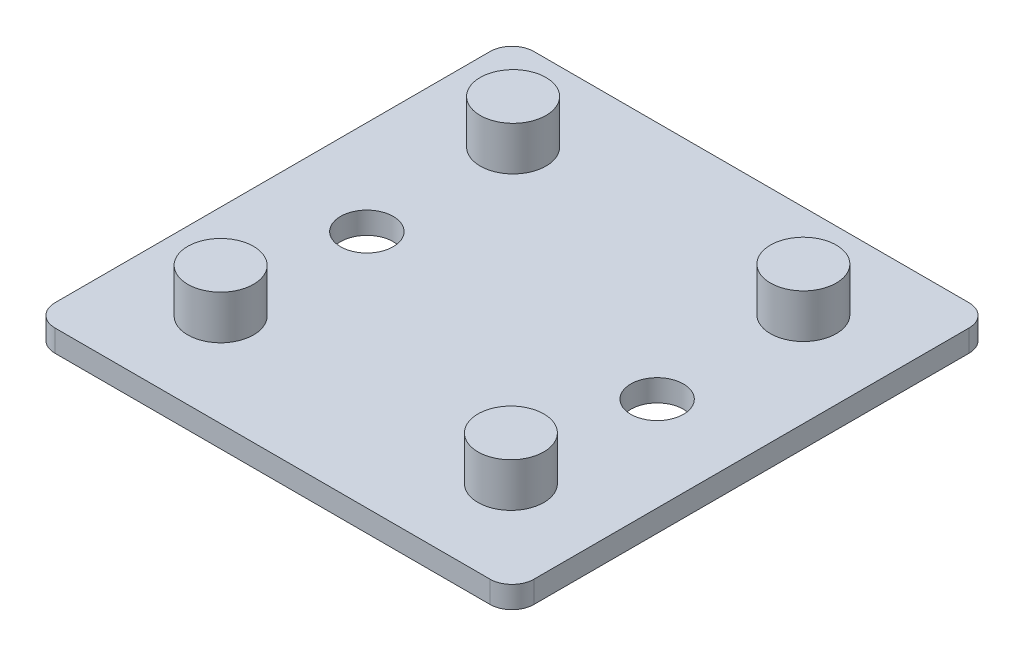
from build123d import *

# Parameters (mm, degrees)
SKETCH1_W               = 65.5
SKETCH1_H               = 65.5
BOSS_EXTRUDE1_DEPTH     = 3
FILLET1_R               = 3
SKETCH2_R               = 3.6
CUT_EXTRUDE1_DEPTH      = 23
SKETCH3_R               = 4.5
BOSS_EXTRUDE2_DEPTH     = 6
SKETCH4_R               = 3.6
CUT_EXTRUDE2_DEPTH      = 7
CUT_EXTRUDE2_DEPTH_BACK = 4


with BuildPart() as part:
    # Sketch1 → Boss-Extrude1 (new body)
    with BuildSketch(Plane(origin=(0, 0, 0), x_dir=(1, 0, 0), z_dir=(0, 1, 0))):
        Rectangle(SKETCH1_W, SKETCH1_H)
    extrude(amount=BOSS_EXTRUDE1_DEPTH)

    # Fillet1
    fillet1_edges = [part.edges().sort_by_distance(p)[0] for p in [
        (-32.75, 1.5, -32.75),
        (32.75, 1.5, -32.75),
        (32.75, 1.5, 32.75),
        (-32.75, 1.5, 32.75),
    ]]
    fillet(fillet1_edges, radius=FILLET1_R)

    # Sketch2 → Cut-Extrude1 (cut)
    with BuildSketch(Plane(origin=(0, 3, 0), x_dir=(1, 0, 0), z_dir=(0, 1, 0))):
        with Locations((19.85, -20)):
            Circle(SKETCH2_R)
        with Locations((19.85, 20)):
            Circle(SKETCH2_R)
    cut_extrude1 = extrude(amount=-CUT_EXTRUDE1_DEPTH, mode=Mode.SUBTRACT)

    # Mirror1: Cut-Extrude1 across plane
    add(cut_extrude1.mirror(Plane(origin=(0, 0, 0), x_dir=(0, 0, 1), z_dir=(1, 0, 0))), mode=Mode.SUBTRACT)

    # Sketch3 → Boss-Extrude2 (add)
    with BuildSketch(Plane(origin=(0, 3, 0), x_dir=(1, 0, 0), z_dir=(0, 1, 0))):
        with Locations((19.85, -20)):
            Circle(SKETCH3_R)
        with Locations((19.85, 20)):
            Circle(SKETCH3_R)
        with Locations((-19.85, 20)):
            Circle(SKETCH3_R)
        with Locations((-19.85, -20)):
            Circle(SKETCH3_R)
    extrude(amount=BOSS_EXTRUDE2_DEPTH)

    # Sketch4 → Cut-Extrude2 (cut, two sides)
    with BuildSketch(Plane(origin=(0, 3, 0), x_dir=(1, 0, 0), z_dir=(0, 1, 0))) as cut_extrude2_sk:
        with Locations((19.85, 0)):
            Circle(SKETCH4_R)
        with Locations((-19.85, 0)):
            Circle(SKETCH4_R)
    extrude(amount=CUT_EXTRUDE2_DEPTH, mode=Mode.SUBTRACT)
    extrude(cut_extrude2_sk.sketch, amount=-CUT_EXTRUDE2_DEPTH_BACK, mode=Mode.SUBTRACT)


solid = part.part
